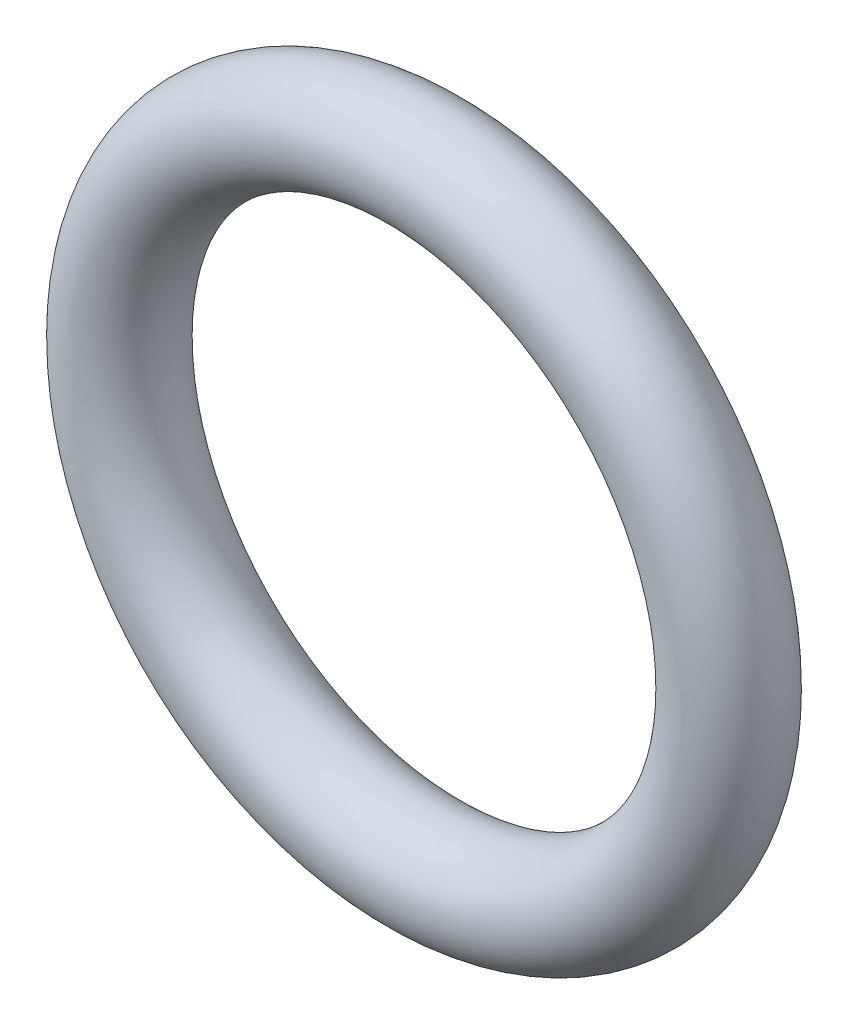
from build123d import *

# Parameters (mm, degrees)
SKETCH2_R = 1.2


with BuildPart() as part:
    # Sweep1: sweep along a path in Sketch1
    with BuildLine(Plane.XY) as sweep1_path:
        CenterArc((0, 0), 5.9, 0, 360)
    # Sketch2 → Sweep1 (sweep)
    with BuildSketch(Plane(origin=(0, 0, 0), x_dir=(1, 0, 0), z_dir=(0, 1, 0))):
        with Locations((-7.1, 0)):
            Circle(SKETCH2_R)
    sweep(path=sweep1_path.line)


solid = part.part
